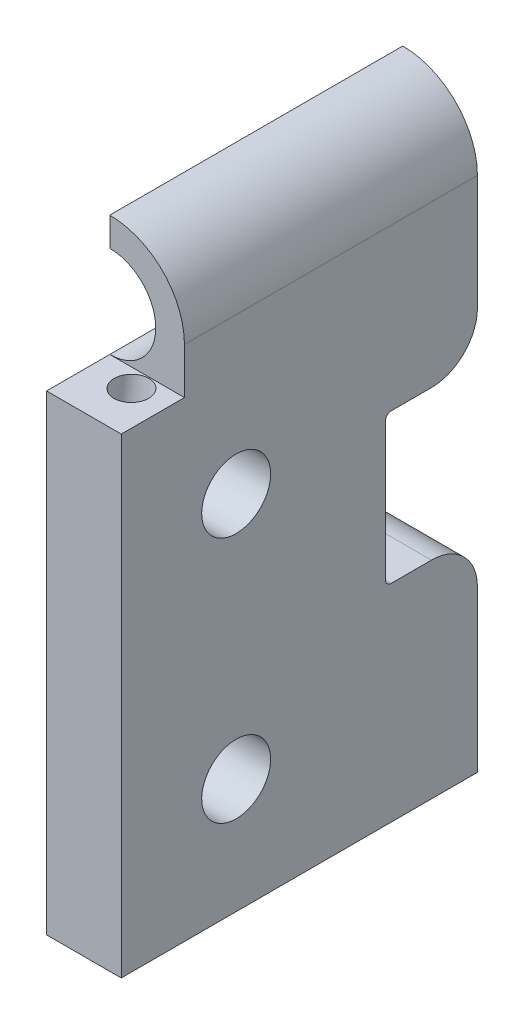
from build123d import *

# Parameters (mm, degrees)
BOSS_EXTRUDE1_DEPTH = 31
SKETCH2_W           = 5.5
SKETCH2_H           = 10.5
CUT_EXTRUDE1_DEPTH  = 7.5
SKETCH3_R           = 3
CUT_EXTRUDE2_DEPTH  = 7.5
CUT_EXTRUDE5_REACH  = 8.5
SKETCH6_W           = 8
SKETCH6_H           = 13
FILLET1_R           = 0.5
FILLET2_R           = 4
CUT_EXTRUDE7_REACH  = 27.5
SKETCH9_R           = 1.5
CUT_EXTRUDE8_DEPTH  = 17


with BuildPart() as part:
    # Sketch1 → Boss-Extrude1 (new body)
    with BuildSketch(Plane.XY):
        with BuildLine():
            Line((-3.75, 29), (-3.75, 22.5))
            Line((-3.75, 22.5), (-3.75, -22.5))
            Line((-3.75, -22.5), (2.75, -22.5))
            Line((2.75, -22.5), (2.75, 22.5))
            ThreePointArc((2.75, 22.5), (0.846194078, 27.096194078), (-3.75, 29))
        make_face()
    extrude(amount=BOSS_EXTRUDE1_DEPTH)

    # Sketch2 → Cut-Extrude1 (cut, through all)
    with BuildSketch(Plane.ZY.offset(3.75)):
        with Locations((28.25, 23.75)):
            Rectangle(SKETCH2_W, SKETCH2_H)
    extrude(amount=-CUT_EXTRUDE1_DEPTH, mode=Mode.SUBTRACT)

    # Sketch3 → Cut-Extrude2 (cut, through all)
    with BuildSketch(Plane.ZY.offset(3.75)):
        with Locations((21, 9)):
            Circle(SKETCH3_R)
        with Locations((21, -12.5)):
            Circle(SKETCH3_R)
    extrude(amount=-CUT_EXTRUDE2_DEPTH, mode=Mode.SUBTRACT)

    # Sketch6 → Cut-Extrude5 (cut, up to next)
    with BuildSketch(Plane.ZY.offset(3.75), mode=Mode.PRIVATE) as cut_extrude5_sk1:
        with Locations((4, 2)):
            Rectangle(SKETCH6_W, SKETCH6_H)
    cut_extrude5_tool1 = extrude(cut_extrude5_sk1.sketch, amount=-CUT_EXTRUDE5_REACH, mode=Mode.PRIVATE) & part.part
    add(cut_extrude5_tool1.solids().sort_by_distance((-3.75, 2, 4))[0], mode=Mode.SUBTRACT)

    # Fillet1
    fillet1_edges = [part.edges().sort_by_distance(p)[0] for p in [
        (-0.5, 8.5, 8),
        (-0.5, -4.5, 8),
    ]]
    fillet(fillet1_edges, radius=FILLET1_R)

    # Fillet2
    fillet2_edges = [part.edges().sort_by_distance(p)[0] for p in [
        (-0.5, -4.5, 0),
        (-0.5, 8.5, 0),
    ]]
    fillet(fillet2_edges, radius=FILLET2_R)

    # Sketch8 → Cut-Extrude7 (cut, up to next)
    with BuildSketch(Plane.XY.offset(25.5), mode=Mode.PRIVATE) as cut_extrude7_sk1:
        with BuildLine():
            Line((-3.75, 26.5), (-3.75, 18.5))
            ThreePointArc((-3.75, 18.5), (0.25, 22.5), (-3.75, 26.5))
        make_face()
    cut_extrude7_tool1 = extrude(cut_extrude7_sk1.sketch, amount=-CUT_EXTRUDE7_REACH, mode=Mode.PRIVATE) & part.part
    add(cut_extrude7_tool1.solids().sort_by_distance((-2.052347, 22.5, 25.5))[0], mode=Mode.SUBTRACT)

    # Sketch9 → Cut-Extrude8 (cut)
    with BuildSketch(Plane(origin=(0, 14.627294401, -2.055732165), x_dir=(-1, 0, 0), z_dir=(0, 0.990268069, -0.139173101))):
        with Locations((0.25, 29.426538121)):
            Circle(SKETCH9_R)
    extrude(amount=-CUT_EXTRUDE8_DEPTH, mode=Mode.SUBTRACT)


solid = part.part
